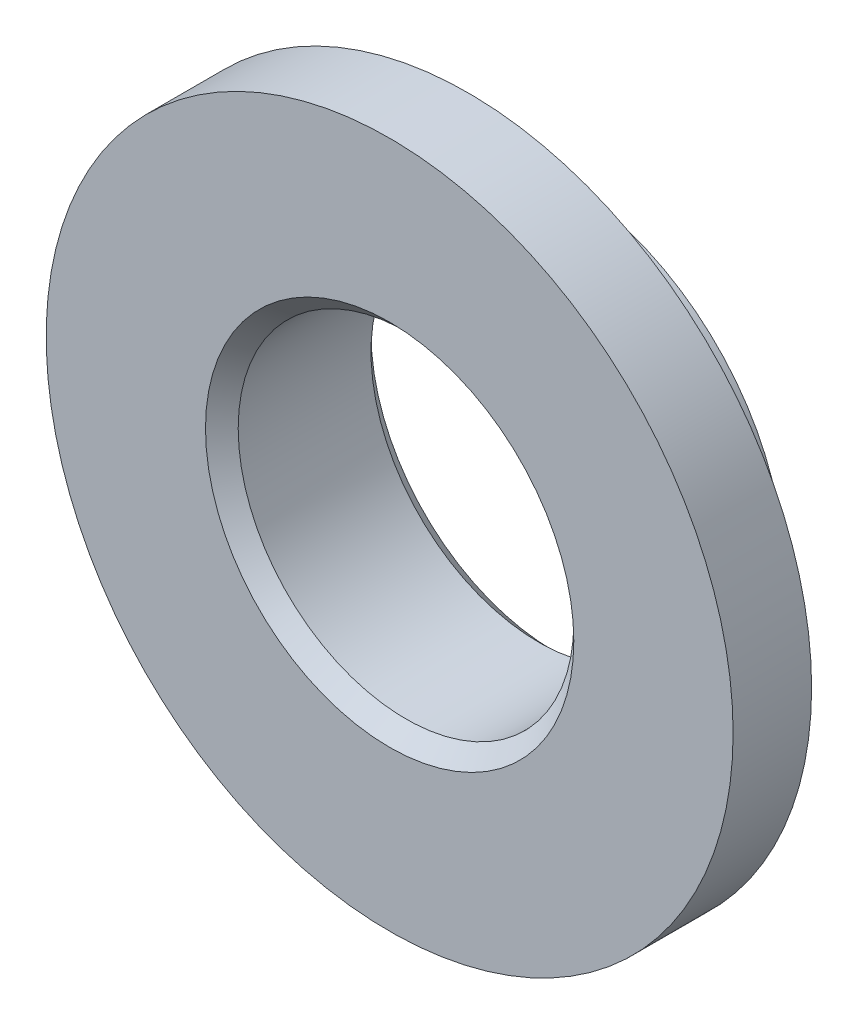
from build123d import *

# Parameters (mm, degrees)
CHANFREIN1_SIZE = 0.5
CHANFREIN2_SIZE = 0.5


with BuildPart() as part:
    # Esquisse1 → Révolution1 (revolve)
    with BuildSketch(Plane(origin=(0, 0, 0), x_dir=(0, 0, -1), z_dir=(1, 0, 0)), mode=Mode.PRIVATE) as r_volution1_sk:
        Polygon((0, 10.5), (0, 5.13), (5.06, 5.13), (5.06, 7), (2.4, 7), (2.4, 10.5), align=None)
    revolve(r_volution1_sk.sketch.rotate(Axis((0, 0, 0), (0, 0, -1)), 90), axis=Axis((0, 0, 0), (0, 0, -1)))  # turned: the seam where the file's is

    # Chanfrein1
    chanfrein1_edges = [part.edges().sort_by_distance(p)[0] for p in [
        (-5.13, 0, 0),
    ]]
    chamfer(chanfrein1_edges, length=CHANFREIN1_SIZE)

    # Chanfrein2
    chanfrein2_edges = [part.edges().sort_by_distance(p)[0] for p in [
        (-5.13, 0, -5.06),
    ]]
    chamfer(chanfrein2_edges, length=CHANFREIN2_SIZE)


solid = part.part
